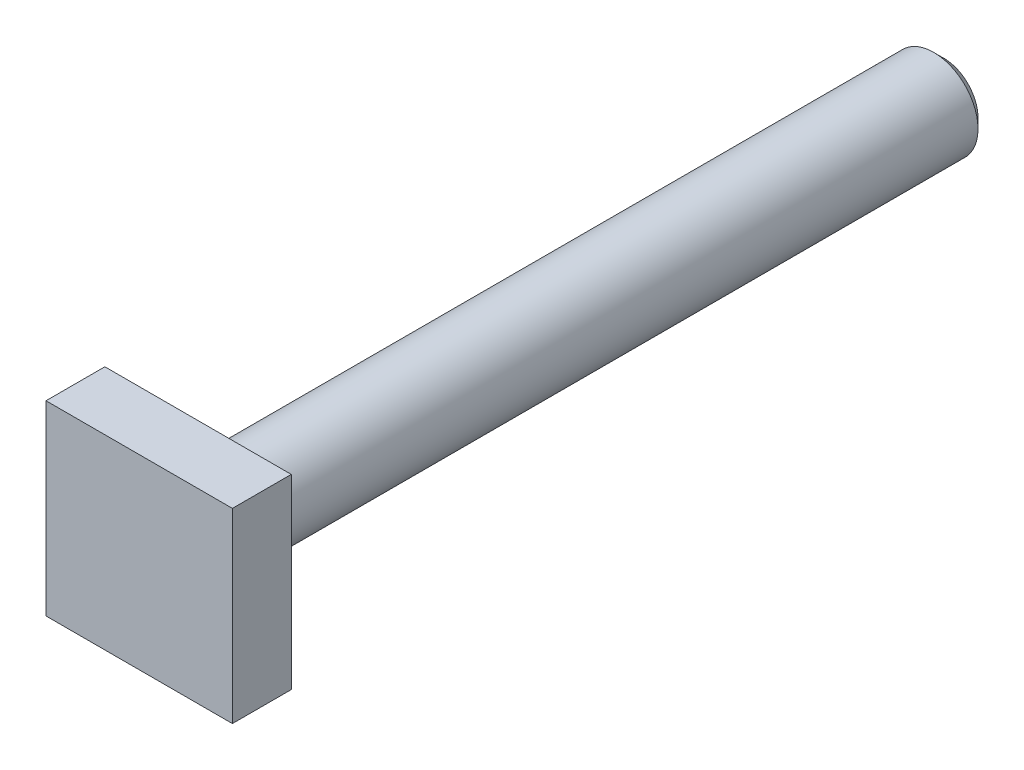
from build123d import *

# Parameters (mm, degrees)
SKETCH1_W           = 19
SKETCH1_H           = 19
BOSS_EXTRUDE1_DEPTH = 6
SKETCH2_R           = 4.5
BOSS_EXTRUDE2_DEPTH = 76
CHAMFER1_SIZE       = 1


with BuildPart() as part:
    # Sketch1 → Boss-Extrude1 (new body)
    with BuildSketch(Plane.XY):
        Rectangle(SKETCH1_W, SKETCH1_H)
    extrude(amount=-BOSS_EXTRUDE1_DEPTH)

    # Sketch2 → Boss-Extrude2 (add)
    with BuildSketch(Plane(origin=(0, 0, -6), x_dir=(-1, 0, 0), z_dir=(0, 0, -1))):
        with Locations(Location((0, 0, 0), (0, 0, 180))):  # turned: the seam where the file's is
            Circle(SKETCH2_R)
    extrude(amount=BOSS_EXTRUDE2_DEPTH)

    # Chamfer1
    chamfer1_edges = [part.edges().sort_by_distance(p)[0] for p in [
        (-4.5, 0, -82),
    ]]
    chamfer(chamfer1_edges, length=CHAMFER1_SIZE)


solid = part.part
